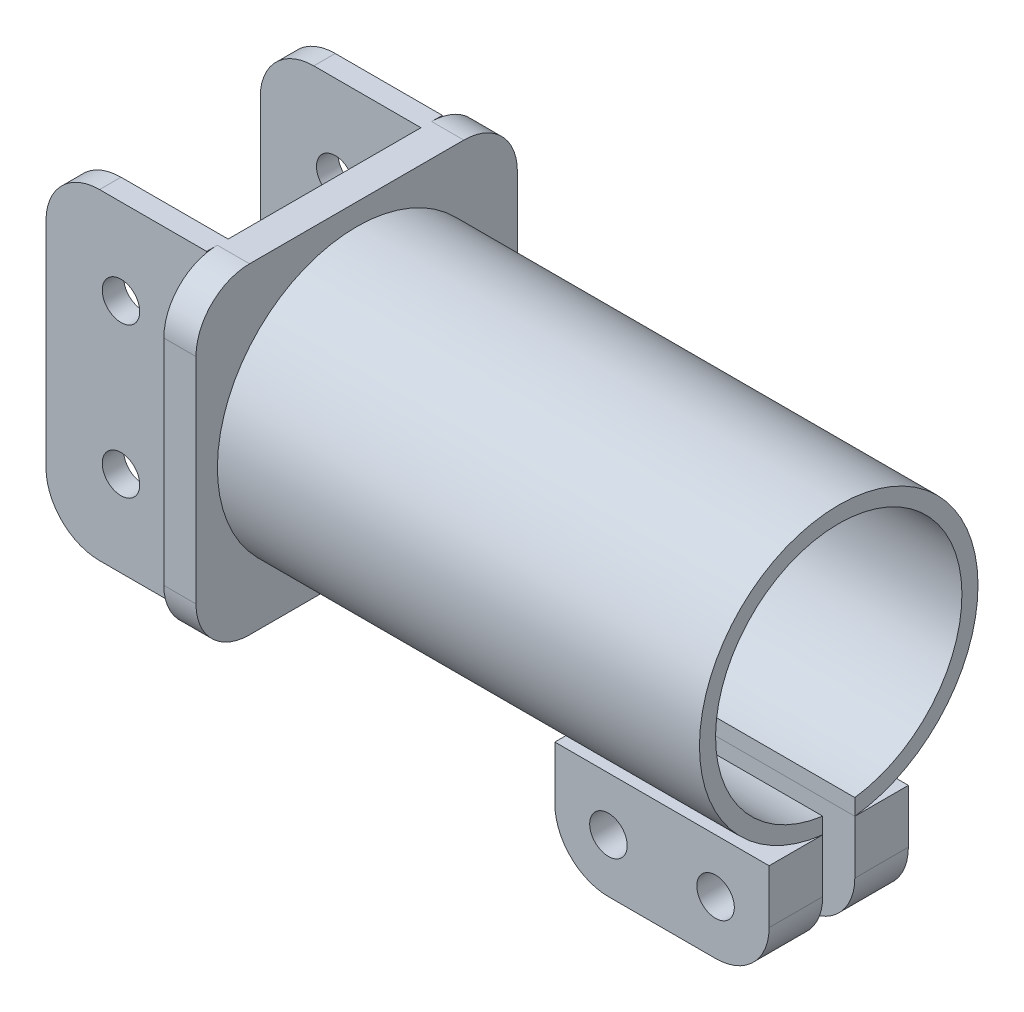
from build123d import *

# Parameters (mm, degrees)
SKETCH1_R            = 13
SKETCH1_R_2          = 11.5
BOSS_EXTRUDE5_DEPTH  = 45
BOSS_EXTRUDE7_DEPTH  = 3
SKETCH6_W            = 2
SKETCH6_H            = 30
BOSS_EXTRUDE8_DEPTH  = 15
SKETCH7_W            = 40
SKETCH7_H            = 9.743944637
CUT_EXTRUDE1_DEPTH   = 1.5
FILLET1_R            = 5
SKETCH8_R            = 1.75
CUT_EXTRUDE2_DEPTH   = 77
SKETCH9_R            = 1.75
BOSS_EXTRUDE9_DEPTH  = 5
SKETCH12_R           = 1.75
BOSS_EXTRUDE10_DEPTH = 5


with BuildPart() as part:
    # Sketch1 → Boss-Extrude5 (new body)
    with BuildSketch(Plane(origin=(0, 0, 0), x_dir=(0, 0, -1), z_dir=(1, 0, 0))):
        Circle(SKETCH1_R)
        Circle(SKETCH1_R_2, mode=Mode.SUBTRACT)
    extrude(amount=BOSS_EXTRUDE5_DEPTH)

    # Sketch5 → Boss-Extrude7 (add)
    with BuildSketch(Plane.ZY):
        with BuildLine():
            Line((-10, 15), (10, 15))
            ThreePointArc((10, 15), (13.535533906, 13.535533906), (15, 10))
            Line((15, 10), (15, -10))
            ThreePointArc((15, -10), (13.535533906, -13.535533906), (10, -15))
            Line((10, -15), (-10, -15))
            ThreePointArc((-10, -15), (-13.535533906, -13.535533906), (-15, -10))
            Line((-15, -10), (-15, 10))
            ThreePointArc((-15, 10), (-13.535533906, 13.535533906), (-10, 15))
        make_face()
    extrude(amount=BOSS_EXTRUDE7_DEPTH)

    # Sketch6 → Boss-Extrude8 (add)
    with BuildSketch(Plane.ZY.offset(3)):
        with Locations((-10, 0)):
            Rectangle(SKETCH6_W, SKETCH6_H)
        with Locations((10, 0)):
            Rectangle(SKETCH6_W, SKETCH6_H)
    extrude(amount=BOSS_EXTRUDE8_DEPTH)

    # Sketch7 → Cut-Extrude1 (cut, symmetric)
    with BuildSketch(Plane.XY):
        with Locations((25, -13.102652826)):
            Rectangle(SKETCH7_W, SKETCH7_H)
    extrude(amount=CUT_EXTRUDE1_DEPTH, both=True, mode=Mode.SUBTRACT)

    # Fillet1
    fillet1_edges = [part.edges().sort_by_distance(p)[0] for p in [
        (-18, -15, -10),
        (-18, 15, -10),
        (-18, -15, 10),
        (-18, 15, 10),
    ]]
    fillet(fillet1_edges, radius=FILLET1_R)

    # Sketch8 → Cut-Extrude2 (cut)
    with BuildSketch(Plane.XY.offset(11)):
        with Locations((-11, 7)):
            Circle(SKETCH8_R)
        with Locations((-11, -7)):
            Circle(SKETCH8_R)
    extrude(amount=-CUT_EXTRUDE2_DEPTH, mode=Mode.SUBTRACT)


with BuildPart() as body_2:
    # Sketch9 → Boss-Extrude9 (new body)
    with BuildSketch(Plane.XY.offset(-1.5)):
        with BuildLine():
            Line((45, -12.91317157), (25, -12.91317157))
            Line((25, -12.91317157), (25, -17.91317157))
            ThreePointArc((25, -17.91317157), (26.464466094, -21.448705476), (30, -22.91317157))
            Line((30, -22.91317157), (40, -22.91317157))
            ThreePointArc((40, -22.91317157), (43.535533906, -21.448705476), (45, -17.91317157))
            Line((45, -17.91317157), (45, -12.91317157))
        make_face()
        with Locations((40, -17.91317157)):
            Circle(SKETCH9_R, mode=Mode.SUBTRACT)
        with Locations((30, -17.91317157)):
            Circle(SKETCH9_R, mode=Mode.SUBTRACT)
    extrude(amount=-BOSS_EXTRUDE9_DEPTH)


with BuildPart() as body_3:
    # Sketch12 → Boss-Extrude10 (new body)
    with BuildSketch(Plane(origin=(0, 0, 1.5), x_dir=(-1, 0, 0), z_dir=(0, 0, -1))):
        with BuildLine():
            Line((-45, -12.91317157), (-45, -17.91317157))
            ThreePointArc((-45, -17.91317157), (-43.535533906, -21.448705476), (-40, -22.91317157))
            Line((-40, -22.91317157), (-30, -22.91317157))
            ThreePointArc((-30, -22.91317157), (-26.464466094, -21.448705476), (-25, -17.91317157))
            Line((-25, -17.91317157), (-25, -12.91317157))
            Line((-25, -12.91317157), (-45, -12.91317157))
        make_face()
        with Locations((-30, -17.91317157)):
            Circle(SKETCH12_R, mode=Mode.SUBTRACT)
        with Locations((-40, -17.91317157)):
            Circle(SKETCH12_R, mode=Mode.SUBTRACT)
    extrude(amount=-BOSS_EXTRUDE10_DEPTH)


solid = Compound([part.part, body_2.part, body_3.part])
